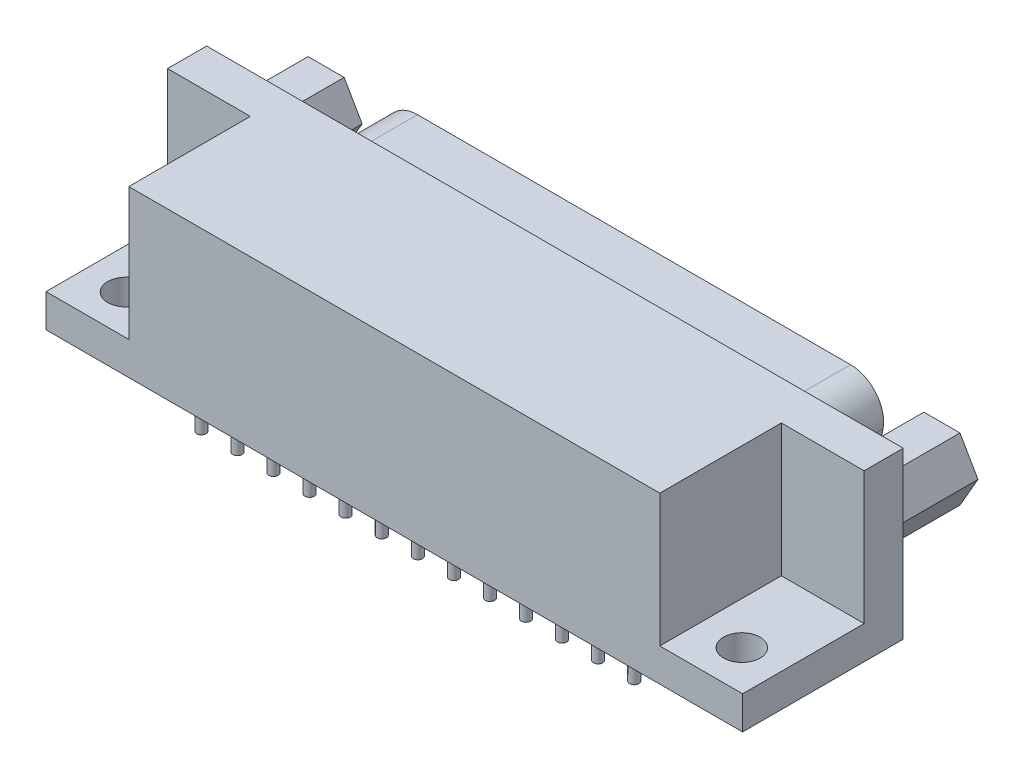
from build123d import *

# Parameters (mm, degrees)
SKETCH1_W           = 53.47
SKETCH1_H           = 12.33
BASE_EXTRUDE_DEPTH  = 12.7
BOSS_EXTRUDE1_DEPTH = 6.07
SKETCH4_R           = 0.5
CUT_EXTRUDE1_DEPTH  = 5.08
SKETCH5_R           = 0.5
CUT_EXTRUDE2_DEPTH  = 5.08
SKETCH6_R           = 0.3556
BOSS_EXTRUDE2_DEPTH = 2.54
LPATTERN1_COUNT     = 13
LPATTERN1_PITCH     = 2.7686
LPATTERN2_COUNT     = 13
LPATTERN2_PITCH     = 2.7686
LPATTERN3_COUNT     = 12
LPATTERN3_PITCH     = 2.7686
SKETCH7_R           = 0.3556
BOSS_EXTRUDE3_DEPTH = 2.54
LPATTERN4_COUNT     = 12
LPATTERN4_PITCH     = 2.7686
SKETCH12_R          = 1.304277921
BOSS_EXTRUDE4_DEPTH = 6.07
SKETCH9_W           = 6.35508
SKETCH9_H           = 10.16
CUT_EXTRUDE3_DEPTH  = 9.33
SKETCH11_R          = 1.4
CUT_EXTRUDE4_DEPTH  = 6.08


with BuildPart() as part:
    # Sketch1 → Base-Extrude (new body)
    with BuildSketch(Plane(origin=(0, 0, 0), x_dir=(1, 0, 0), z_dir=(0, 1, 0))):
        with Locations((16.575, 4.395)):
            Rectangle(SKETCH1_W, SKETCH1_H)
    extrude(amount=BASE_EXTRUDE_DEPTH)

    # Sketch2 → Boss-Extrude1 (add)
    with BuildSketch(Plane(origin=(0, 0, -10.56), x_dir=(-1, 0, 0), z_dir=(0, 0, -1))):
        with BuildLine():
            Line((-32.654431338, 2.286), (-0.495568662, 2.286))
            ThreePointArc((-0.495568662, 2.286), (1.120925043, 2.8667787), (1.998186376, 4.34352118))
            Line((1.998186376, 4.34352118), (2.538755038, 7.13752118))
            ThreePointArc((2.538755038, 7.13752118), (2.0042213, 9.236493705), (0.045, 10.16))
            Line((0.045, 10.16), (-33.195, 10.16))
            ThreePointArc((-33.195, 10.16), (-35.1542213, 9.236493705), (-35.688755038, 7.13752118))
            Line((-35.688755038, 7.13752118), (-35.148186376, 4.34352118))
            ThreePointArc((-35.148186376, 4.34352118), (-34.270925043, 2.8667787), (-32.654431338, 2.286))
        make_face()
    extrude(amount=BOSS_EXTRUDE1_DEPTH)

    # Sketch4 → Cut-Extrude1 (cut)
    with BuildSketch(Plane(origin=(0, 0, -16.63), x_dir=(-1, 0, 0), z_dir=(0, 0, -1))):
        with Locations((0, 7.62)):
            Circle(SKETCH4_R)
    cut_extrude1 = extrude(amount=-CUT_EXTRUDE1_DEPTH, mode=Mode.SUBTRACT)

    # Sketch5 → Cut-Extrude2 (cut)
    with BuildSketch(Plane(origin=(0, 0, -16.63), x_dir=(-1, 0, 0), z_dir=(0, 0, -1))):
        with Locations((-1.397, 5.08)):
            Circle(SKETCH5_R)
    cut_extrude2 = extrude(amount=-CUT_EXTRUDE2_DEPTH, mode=Mode.SUBTRACT)

    # Sketch6 → Boss-Extrude2 (add)
    with BuildSketch(Plane.XZ):
        Circle(SKETCH6_R)
    boss_extrude2 = extrude(amount=BOSS_EXTRUDE2_DEPTH)

    # LPattern1: Boss-Extrude2 ×13
    with Locations(*[(i * LPATTERN1_PITCH, 0, 0) for i in range(1, LPATTERN1_COUNT)]):
        add(boss_extrude2)

    # LPattern2: Cut-Extrude1 ×13
    with Locations(*[(i * LPATTERN2_PITCH, 0, 0) for i in range(1, LPATTERN2_COUNT)]):
        add(cut_extrude1, mode=Mode.SUBTRACT)

    # LPattern3: Cut-Extrude2 ×12
    with Locations(*[(i * LPATTERN3_PITCH, 0, 0) for i in range(1, LPATTERN3_COUNT)]):
        add(cut_extrude2, mode=Mode.SUBTRACT)

    # Sketch7 → Boss-Extrude3 (add)
    with BuildSketch(Plane.XZ):
        with Locations((1.397, -2.54)):
            Circle(SKETCH7_R)
    boss_extrude3 = extrude(amount=BOSS_EXTRUDE3_DEPTH)

    # LPattern4: Boss-Extrude3 ×12
    with Locations(*[(i * LPATTERN4_PITCH, 0, 0) for i in range(1, LPATTERN4_COUNT)]):
        add(boss_extrude3)

    # Sketch12 → Boss-Extrude4 (add)
    with BuildSketch(Plane(origin=(0, 0, -10.56), x_dir=(-1, 0, 0), z_dir=(0, 0, -1))):
        Polygon((-41.595, 9.82), (-42.98, 7.421109632), (-41.595, 5.022219263), (-38.825, 5.022219263), (-37.44, 7.421109632), (-38.825, 9.82), align=None)
        with Locations((-40.21, 7.421109632)):
            Circle(SKETCH12_R, mode=Mode.SUBTRACT)
    boss_extrude4 = extrude(amount=BOSS_EXTRUDE4_DEPTH)

    # Sketch9 → Cut-Extrude3 (cut)
    with BuildSketch(Plane.XY.offset(1.77)):
        with Locations((-6.98246, 7.62)):
            Rectangle(SKETCH9_W, SKETCH9_H)
    cut_extrude3 = extrude(amount=-CUT_EXTRUDE3_DEPTH, mode=Mode.SUBTRACT)

    # Sketch11 → Cut-Extrude4 (cut, through all)
    with BuildSketch(Plane(origin=(0, 2.54, 0), x_dir=(-1, 0, 0), z_dir=(0, 1, 0))):
        with Locations((7.06, -1.27)):
            Circle(SKETCH11_R)
    cut_extrude4 = extrude(amount=-CUT_EXTRUDE4_DEPTH, mode=Mode.SUBTRACT)

    # Mirror1: Boss-Extrude4, Cut-Extrude3, Cut-Extrude4 across plane
    add(boss_extrude4.mirror(Plane(origin=(16.575, 0, 0), x_dir=(0, 0, 1), z_dir=(1, 0, 0))))
    add(cut_extrude3.mirror(Plane(origin=(16.575, 0, 0), x_dir=(0, 0, 1), z_dir=(1, 0, 0))), mode=Mode.SUBTRACT)
    add(cut_extrude4.mirror(Plane(origin=(16.575, 0, 0), x_dir=(0, 0, 1), z_dir=(1, 0, 0))), mode=Mode.SUBTRACT)


solid = part.part
